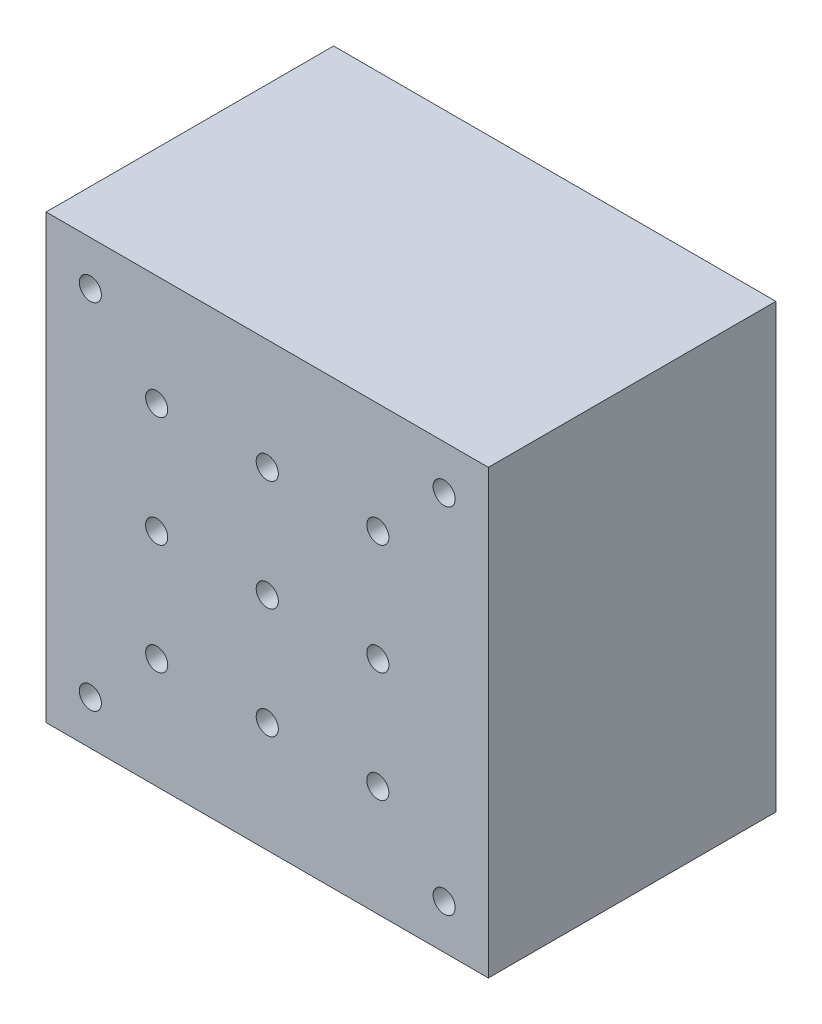
from build123d import *

# Parameters (mm, degrees)
SKETCH1_W                     = 127
SKETCH1_H                     = 127
BOSS_EXTRUDE1_DEPTH           = 82.55
SKETCH2_R                     = 3.175
CUT_EXTRUDE1_DEPTH            = 83.55
LPATTERN1_COUNT               = 2
LPATTERN1_PITCH               = 31.75
LPATTERN1_COL_COUNT           = 2
LPATTERN1_COL_PITCH           = 31.75
LPATTERN2_COUNT               = 2
LPATTERN2_PITCH               = 31.75
LPATTERN2_COPY_1_SKETCH_R     = 3.175
LPATTERN2_COPY_1_DEPTH        = 83.55
LPATTERN2_COPY_2_SKETCH_R     = 3.175
LPATTERN2_COPY_2_DEPTH        = 83.55
LPATTERN2_COL_COUNT           = 2
LPATTERN2_COL_PITCH           = 31.75
LPATTERN2_COL_COPY_1_SKETCH_R = 3.175
LPATTERN2_COL_COPY_1_DEPTH    = 83.55
LPATTERN2_COL_COPY_2_SKETCH_R = 3.175
LPATTERN2_COL_COPY_2_DEPTH    = 83.55
SKETCH3_R                     = 3.175
CUT_EXTRUDE2_DEPTH            = 83.55


with BuildPart() as part:
    # Sketch1 → Boss-Extrude1 (new body)
    with BuildSketch(Plane.XY):
        Rectangle(SKETCH1_W, SKETCH1_H)
    extrude(amount=BOSS_EXTRUDE1_DEPTH)

    # Sketch2 → Cut-Extrude1 (cut, through all)
    with BuildSketch(Plane.XY.offset(82.55)):
        Circle(SKETCH2_R)
    cut_extrude1 = extrude(amount=-CUT_EXTRUDE1_DEPTH, mode=Mode.SUBTRACT)

    # LPattern1: Cut-Extrude1 ×2
    with Locations(*[(-i * LPATTERN1_PITCH, 0, 0) for i in range(1, LPATTERN1_COUNT)]):
        add(cut_extrude1, mode=Mode.SUBTRACT)

    # LPattern1 col: Cut-Extrude1 ×2
    with Locations(*[(i * LPATTERN1_COL_PITCH, 0, 0) for i in range(1, LPATTERN1_COL_COUNT)]):
        add(cut_extrude1, mode=Mode.SUBTRACT)

    # LPattern2: Cut-Extrude1 ×2
    with Locations(*[(0, -i * LPATTERN2_PITCH, 0) for i in range(1, LPATTERN2_COUNT)]):
        add(cut_extrude1, mode=Mode.SUBTRACT)

    # LPattern2 copy 1 sketch → LPattern2 copy 1 (cut, through all)
    with BuildSketch(Plane(origin=(-31.75, -31.75, 82.55), x_dir=(1, 0, 0), z_dir=(0, 0, 1))):
        Circle(LPATTERN2_COPY_1_SKETCH_R)
    extrude(amount=-LPATTERN2_COPY_1_DEPTH, mode=Mode.SUBTRACT)

    # LPattern2 copy 2 sketch → LPattern2 copy 2 (cut, through all)
    with BuildSketch(Plane(origin=(31.75, -31.75, 82.55), x_dir=(1, 0, 0), z_dir=(0, 0, 1))):
        Circle(LPATTERN2_COPY_2_SKETCH_R)
    extrude(amount=-LPATTERN2_COPY_2_DEPTH, mode=Mode.SUBTRACT)

    # LPattern2 col: Cut-Extrude1 ×2
    with Locations(*[(0, i * LPATTERN2_COL_PITCH, 0) for i in range(1, LPATTERN2_COL_COUNT)]):
        add(cut_extrude1, mode=Mode.SUBTRACT)

    # LPattern2 col copy 1 sketch → LPattern2 col copy 1 (cut, through all)
    with BuildSketch(Plane(origin=(-31.75, 31.75, 82.55), x_dir=(1, 0, 0), z_dir=(0, 0, 1))):
        Circle(LPATTERN2_COL_COPY_1_SKETCH_R)
    extrude(amount=-LPATTERN2_COL_COPY_1_DEPTH, mode=Mode.SUBTRACT)

    # LPattern2 col copy 2 sketch → LPattern2 col copy 2 (cut, through all)
    with BuildSketch(Plane(origin=(31.75, 31.75, 82.55), x_dir=(1, 0, 0), z_dir=(0, 0, 1))):
        Circle(LPATTERN2_COL_COPY_2_SKETCH_R)
    extrude(amount=-LPATTERN2_COL_COPY_2_DEPTH, mode=Mode.SUBTRACT)

    # Sketch3 → Cut-Extrude2 (cut, through all)
    with BuildSketch(Plane.XY.offset(82.55)):
        with Locations((-50.8, 50.8)):
            Circle(SKETCH3_R)
        with Locations((50.8, 50.8)):
            Circle(SKETCH3_R)
        with Locations((50.8, -50.8)):
            Circle(SKETCH3_R)
        with Locations((-50.8, -50.8)):
            Circle(SKETCH3_R)
    extrude(amount=-CUT_EXTRUDE2_DEPTH, mode=Mode.SUBTRACT)


solid = part.part
